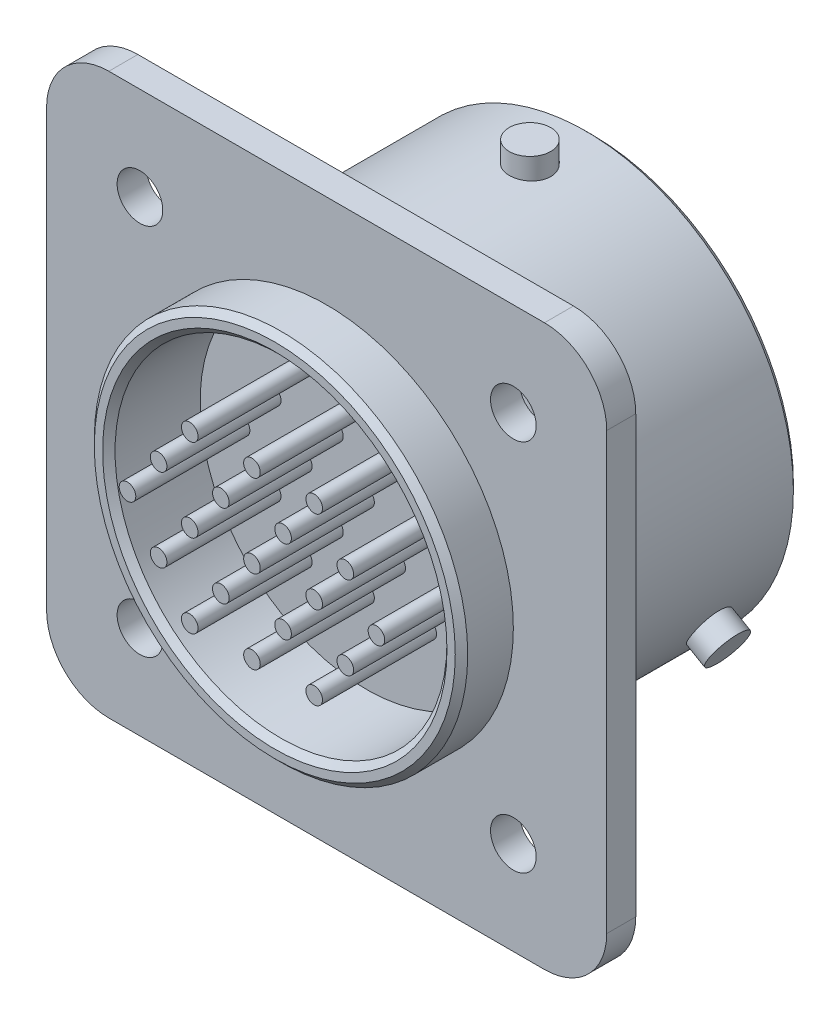
from build123d import *

# Parameters (mm, degrees)
SKETCH_1_R               = 9
EXTRUDE_1_DEPTH          = 2.5
SKETCH_2_R               = 1.1
EXTRUDE_2_DEPTH          = 1.4
SKETCH_3_R               = 10
EXTRUDE_3_DEPTH          = 11.4
SKETCH_4_R               = 8
CUT_EXTRUDE_1_DEPTH      = 4.4
SKETCH_5_R               = 9
CUT_EXTRUDE_2_DEPTH      = 7.4
SKETCH_6_R               = 8
EXTRUDE_4_DEPTH          = 1
SKETCH_7_R               = 0.4
EXTRUDE_5_DEPTH          = 5.5
EXTRUDE_5_DEPTH_BACK     = 10
CHAMFER_1_SIZE           = 0.3
EXTRUDE_START            = 9.949874
SKETCH_8_R               = 1
EXTRUDE_6_DEPTH          = 1.050126
PATTERN_CIRCULAR_1_COUNT = 3


with BuildPart() as part:
    # Эскиз1 → Бобышка-Вытянуть1 (new body)
    with BuildSketch(Plane.XY):
        Circle(SKETCH_1_R)
    extrude(amount=EXTRUDE_1_DEPTH)

    # Эскиз2 → Бобышка-Вытянуть2 (add)
    with BuildSketch(Plane(origin=(0, 0, 0), x_dir=(-1, 0, 0), z_dir=(0, 0, -1))):
        with BuildLine():
            Line((10.5, -13.5), (-10.5, -13.5))
            ThreePointArc((-10.5, -13.5), (-12.621320344, -12.621320344), (-13.5, -10.5))
            Line((-13.5, -10.5), (-13.5, 10.5))
            ThreePointArc((-13.5, 10.5), (-12.621320344, 12.621320344), (-10.5, 13.5))
            Line((-10.5, 13.5), (10.5, 13.5))
            ThreePointArc((10.5, 13.5), (12.621320344, 12.621320344), (13.5, 10.5))
            Line((13.5, 10.5), (13.5, -10.5))
            ThreePointArc((13.5, -10.5), (12.621320344, -12.621320344), (10.5, -13.5))
        make_face()
        with Locations((9, 9)):
            Circle(SKETCH_2_R, mode=Mode.SUBTRACT)
        with Locations((-9, 9)):
            Circle(SKETCH_2_R, mode=Mode.SUBTRACT)
        with Locations((9, -9)):
            Circle(SKETCH_2_R, mode=Mode.SUBTRACT)
        with Locations((-9, -9)):
            Circle(SKETCH_2_R, mode=Mode.SUBTRACT)
    extrude(amount=EXTRUDE_2_DEPTH)

    # Эскиз3 → Бобышка-Вытянуть3 (add)
    with BuildSketch(Plane(origin=(0, 0, -1.4), x_dir=(-1, 0, 0), z_dir=(0, 0, -1))):
        with Locations(Location((0, 0, 0), (0, 0, 180))):
            Circle(SKETCH_3_R)
    extrude(amount=EXTRUDE_3_DEPTH)

    # Эскиз4 → Вырез-Вытянуть1 (cut)
    with BuildSketch(Plane.XY.offset(2.5)):
        Circle(SKETCH_4_R)
    extrude(amount=-CUT_EXTRUDE_1_DEPTH, mode=Mode.SUBTRACT)

    # Эскиз5 → Вырез-Вытянуть2 (cut)
    with BuildSketch(Plane(origin=(0, 0, -12.8), x_dir=(-1, 0, 0), z_dir=(0, 0, -1))):
        with Locations(Location((0, 0, 0), (0, 0, 180))):
            Circle(SKETCH_5_R)
    extrude(amount=-CUT_EXTRUDE_2_DEPTH, mode=Mode.SUBTRACT)

    # Эскиз6 → Бобышка-Вытянуть4 (add)
    with BuildSketch(Plane(origin=(0, 0, -5.4), x_dir=(-1, 0, 0), z_dir=(0, 0, -1))):
        with Locations(Location((0, 0, 0), (0, 0, 180))):
            Circle(SKETCH_6_R)
    extrude(amount=EXTRUDE_4_DEPTH)

    # Эскиз7 → Бобышка-Вытянуть5 (add, two sides)
    with BuildSketch(Plane(origin=(0, 0, -6.4), x_dir=(-1, 0, 0), z_dir=(0, 0, -1))) as extrude_5_sk:
        Circle(SKETCH_7_R)
        with Locations((3, 0)):
            Circle(SKETCH_7_R)
        with Locations((6, 0)):
            Circle(SKETCH_7_R)
        with Locations((4.5, 2)):
            Circle(SKETCH_7_R)
        with Locations((-3, 0)):
            Circle(SKETCH_7_R)
        with Locations((-6, 0)):
            Circle(SKETCH_7_R)
        with Locations((-4.5, 2)):
            Circle(SKETCH_7_R)
        with Locations((-1.5, 2)):
            Circle(SKETCH_7_R)
        with Locations((1.5, 2)):
            Circle(SKETCH_7_R)
        with Locations((-3, 4)):
            Circle(SKETCH_7_R)
        with Locations((3, 4)):
            Circle(SKETCH_7_R)
        with Locations((0, 4)):
            Circle(SKETCH_7_R)
        with Locations((0, -4)):
            Circle(SKETCH_7_R)
        with Locations((3, -4)):
            Circle(SKETCH_7_R)
        with Locations((-3, -4)):
            Circle(SKETCH_7_R)
        with Locations((1.5, -2)):
            Circle(SKETCH_7_R)
        with Locations((-1.5, -2)):
            Circle(SKETCH_7_R)
        with Locations((-4.5, -2)):
            Circle(SKETCH_7_R)
        with Locations((4.5, -2)):
            Circle(SKETCH_7_R)
    extrude(amount=EXTRUDE_5_DEPTH)
    extrude(extrude_5_sk.sketch, amount=-EXTRUDE_5_DEPTH_BACK)

    # Фаска1
    chamfer_1_edges = [part.edges().sort_by_distance(p)[0] for p in [
        (-10, 0, -12.8),
        (-8, 0, 2.5),
        (-9, 0, 2.5),
        (-9, 0, -12.8),
    ]]
    chamfer(chamfer_1_edges, length=CHAMFER_1_SIZE)

    # Эскиз8 → Бобышка-Вытянуть6 (add)
    with BuildSketch(Plane(origin=(0, 0, 0), x_dir=(1, 0, 0), z_dir=(0, 1, 0)).offset(EXTRUDE_START)):
        with Locations(Location((0, 9.8, 0), (0, 0, 90))):
            Circle(SKETCH_8_R)
    extrude_6 = extrude(amount=EXTRUDE_6_DEPTH)

    # Круговой массив1: Бобышка-Вытянуть6 ×3 about axis
    pattern_circular_1_axis = Axis((0, 0, 0), (0, 0, 1))
    for i in range(1, PATTERN_CIRCULAR_1_COUNT):
        add(extrude_6.rotate(pattern_circular_1_axis, i * 360 / PATTERN_CIRCULAR_1_COUNT))


solid = part.part
